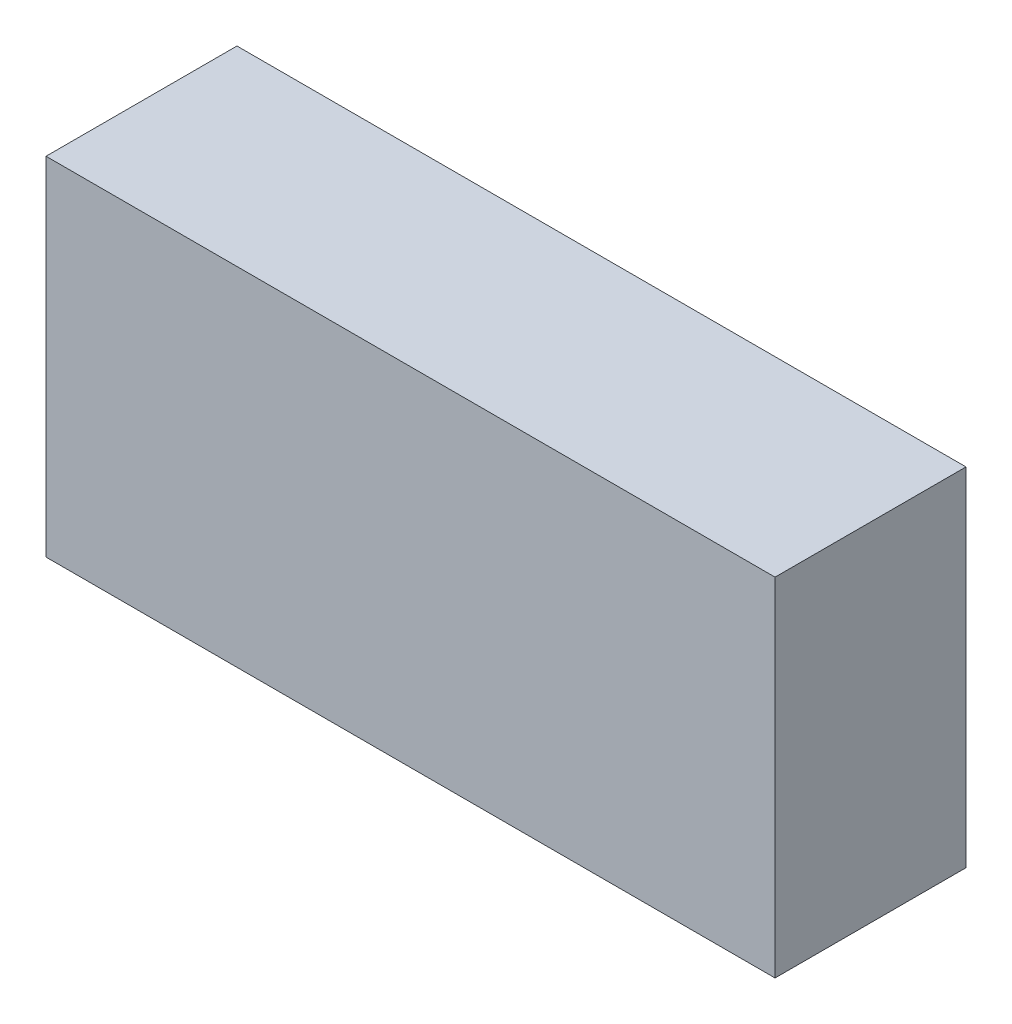
from build123d import *

# Parameters (mm, degrees)
ESQUISSE1_W        = 210
ESQUISSE1_H        = 100
BOSS_EXTRU_1_DEPTH = 55


with BuildPart() as part:
    # Esquisse1 → Boss.-Extru.1 (new body)
    with BuildSketch(Plane.XY):
        with Locations((11.955971461, -9.088606848)):
            Rectangle(ESQUISSE1_W, ESQUISSE1_H)
    extrude(amount=BOSS_EXTRU_1_DEPTH)


solid = part.part
